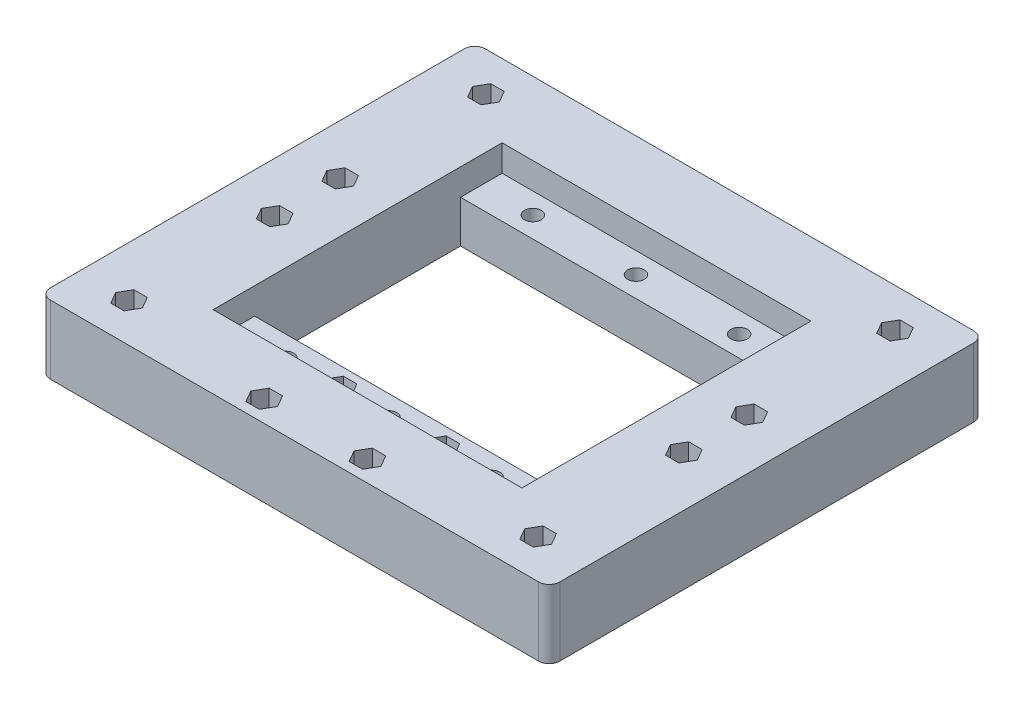
from build123d import *

# Parameters (mm, degrees)
SKETCH2_W               = 122.555
SKETCH2_H               = 104.648
SKETCH2_R               = 2
SKETCH2_W_2             = 74.295
SKETCH2_H_2             = 69.53
BOSS_EXTRUDE5_DEPTH     = 16.51
SKETCH2_4_W             = 74.295
SKETCH2_4_H             = 10
SKETCH2_4_R             = 2
BOSS_EXTRUDE7_DEPTH     = 10.16
CUT_EXTRUDE1_START      = -16.51
SKETCH3_R               = 2
CUT_EXTRUDE1_DEPTH      = 6.35
FILLET1_R               = 2.54
CUT_EXTRUDE2_START      = -10.16
SKETCH4_R               = 2
CUT_EXTRUDE2_DEPTH      = 6.35
SKETCH5_R               = 2
CUT_EXTRUDE3_DEPTH      = 6.35
SKETCH6_R               = 2
CUT_EXTRUDE4_DEPTH      = 6.35
SKETCH7_R               = 2.254
SKETCH7_R_2             = 2
SUPPORTS_3D_PRINT_DEPTH = 6.35


with BuildPart() as part:
    # Sketch2 → Boss-Extrude5 (new body)
    with BuildSketch(Plane(origin=(0, 0, 0), x_dir=(1, 0, 0), z_dir=(0, 1, 0))):
        with Locations((61.2775, 52.324)):
            Rectangle(SKETCH2_W, SKETCH2_H)
        with Locations((12.065, 95.25)):
            Circle(SKETCH2_R, mode=Mode.SUBTRACT)
        with Locations((12.065, 60.198)):
            Circle(SKETCH2_R, mode=Mode.SUBTRACT)
        with Locations((12.065, 44.45)):
            Circle(SKETCH2_R, mode=Mode.SUBTRACT)
        with Locations((12.065, 9.398)):
            Circle(SKETCH2_R, mode=Mode.SUBTRACT)
        with Locations((110.49, 9.398)):
            Circle(SKETCH2_R, mode=Mode.SUBTRACT)
        with Locations((110.49, 44.45)):
            Circle(SKETCH2_R, mode=Mode.SUBTRACT)
        with Locations((110.49, 60.198)):
            Circle(SKETCH2_R, mode=Mode.SUBTRACT)
        with Locations((110.49, 95.25)):
            Circle(SKETCH2_R, mode=Mode.SUBTRACT)
        with Locations((73.744666667, 5.08)):
            Circle(SKETCH2_R, mode=Mode.SUBTRACT)
        with Locations((48.839129454, 5.150105129)):
            Circle(SKETCH2_R, mode=Mode.SUBTRACT)
        with Locations((61.2775, 52.324)):
            Rectangle(SKETCH2_W_2, SKETCH2_H_2, mode=Mode.SUBTRACT)
    extrude(amount=BOSS_EXTRUDE5_DEPTH)

    # Sketch2_4 → Boss-Extrude7 (add)
    with BuildSketch(Plane(origin=(0, 0, 0), x_dir=(1, 0, 0), z_dir=(0, 1, 0))):
        with Locations((61.2775, 22.559)):
            Rectangle(SKETCH2_4_W, SKETCH2_4_H)
        with Locations((36.533666667, 22.559)):
            Circle(SKETCH2_4_R, mode=Mode.SUBTRACT)
        with Locations((48.939224409, 22.929823378)):
            Circle(SKETCH2_4_R, mode=Mode.SUBTRACT)
        with Locations((61.341, 22.559)):
            Circle(SKETCH2_4_R, mode=Mode.SUBTRACT)
        with Locations((73.744666667, 22.86)):
            Circle(SKETCH2_4_R, mode=Mode.SUBTRACT)
        with Locations((86.148333333, 22.559)):
            Circle(SKETCH2_4_R, mode=Mode.SUBTRACT)
        with Locations((61.2775, 82.089)):
            Rectangle(SKETCH2_4_W, SKETCH2_4_H)
        with Locations((36.533666667, 82.089)):
            Circle(SKETCH2_4_R, mode=Mode.SUBTRACT)
        with Locations((61.341, 82.089)):
            Circle(SKETCH2_4_R, mode=Mode.SUBTRACT)
        with Locations((86.148333333, 82.089)):
            Circle(SKETCH2_4_R, mode=Mode.SUBTRACT)
    extrude(amount=BOSS_EXTRUDE7_DEPTH)

    # Sketch3 → Cut-Extrude1 (cut)
    with BuildSketch(Plane.XZ.offset(CUT_EXTRUDE1_START)):
        Polygon((13.678116652, -6.604), (10.451883348, -6.604), (8.838766696, -9.398), (10.451883348, -12.192), (13.678116652, -12.192), (15.291233304, -9.398), align=None)
        with Locations((12.065, -9.398)):
            Circle(SKETCH3_R, mode=Mode.SUBTRACT)
        Polygon((13.678116652, -92.456), (10.451883348, -92.456), (8.838766696, -95.25), (10.451883348, -98.044), (13.678116652, -98.044), (15.291233304, -95.25), align=None)
        with Locations((12.065, -95.25)):
            Circle(SKETCH3_R, mode=Mode.SUBTRACT)
        Polygon((112.103116652, -92.456), (108.876883348, -92.456), (107.263766696, -95.25), (108.876883348, -98.044), (112.103116652, -98.044), (113.716233304, -95.25), align=None)
        with Locations((110.49, -95.25)):
            Circle(SKETCH3_R, mode=Mode.SUBTRACT)
        Polygon((108.876883348, -12.192), (112.103116652, -12.192), (113.716233304, -9.398), (112.103116652, -6.604), (108.876883348, -6.604), (107.263766696, -9.398), align=None)
        with Locations((110.49, -9.398)):
            Circle(SKETCH3_R, mode=Mode.SUBTRACT)
        Polygon((13.678116652, -62.992), (15.291233304, -60.198), (13.678116652, -57.404), (10.451883348, -57.404), (8.838766696, -60.198), (10.451883348, -62.992), align=None)
        with Locations((12.065, -60.198)):
            Circle(SKETCH3_R, mode=Mode.SUBTRACT)
        Polygon((8.838766696, -44.45), (10.451883348, -47.244), (13.678116652, -47.244), (15.291233304, -44.45), (13.678116652, -41.656), (10.451883348, -41.656), align=None)
        with Locations((12.065, -44.45)):
            Circle(SKETCH3_R, mode=Mode.SUBTRACT)
        Polygon((107.263766696, -44.45), (108.876883348, -47.244), (112.103116652, -47.244), (113.716233304, -44.45), (112.103116652, -41.656), (108.876883348, -41.656), align=None)
        with Locations((110.49, -44.45)):
            Circle(SKETCH3_R, mode=Mode.SUBTRACT)
        Polygon((108.876883348, -57.404), (107.263766696, -60.198), (108.876883348, -62.992), (112.103116652, -62.992), (113.716233304, -60.198), (112.103116652, -57.404), align=None)
        with Locations((110.49, -60.198)):
            Circle(SKETCH3_R, mode=Mode.SUBTRACT)
    extrude(amount=CUT_EXTRUDE1_DEPTH, mode=Mode.SUBTRACT)

    # Fillet1
    fillet1_edges = [part.edges().sort_by_distance(p)[0] for p in [
        (0, 8.255, 0),
        (0, 8.255, -104.648),
        (122.555, 8.255, -104.648),
        (122.555, 8.255, 0),
    ]]
    fillet(fillet1_edges, radius=FILLET1_R)

    # Sketch4 → Cut-Extrude2 (cut)
    with BuildSketch(Plane(origin=(0, 10.16, 0), x_dir=(1, 0, 0), z_dir=(0, 1, 0)).offset(CUT_EXTRUDE2_START)):
        Polygon((39.759899971, 22.559), (38.146783319, 25.353), (34.920550015, 25.353), (33.307433362, 22.559), (34.920550015, 19.765), (38.146783319, 19.765), align=None)
        with Locations((36.533666667, 22.559)):
            Circle(SKETCH4_R, mode=Mode.SUBTRACT)
        Polygon((58.114766696, 22.559), (59.727883348, 19.765), (62.954116652, 19.765), (64.567233304, 22.559), (62.954116652, 25.353), (59.727883348, 25.353), align=None)
        with Locations((61.341, 22.559)):
            Circle(SKETCH4_R, mode=Mode.SUBTRACT)
        Polygon((82.922100029, 22.559), (84.535216681, 19.765), (87.761449985, 19.765), (89.374566638, 22.559), (87.761449985, 25.353), (84.535216681, 25.353), align=None)
        with Locations((86.148333333, 22.559)):
            Circle(SKETCH4_R, mode=Mode.SUBTRACT)
        Polygon((82.922100029, 82.089), (84.535216681, 79.295), (87.761449985, 79.295), (89.374566638, 82.089), (87.761449985, 84.883), (84.535216681, 84.883), align=None)
        with Locations((86.148333333, 82.089)):
            Circle(SKETCH4_R, mode=Mode.SUBTRACT)
        Polygon((64.567233304, 82.089), (62.954116652, 84.883), (59.727883348, 84.883), (58.114766696, 82.089), (59.727883348, 79.295), (62.954116652, 79.295), align=None)
        with Locations((61.341, 82.089)):
            Circle(SKETCH4_R, mode=Mode.SUBTRACT)
        Polygon((39.759899971, 82.089), (38.146783319, 84.883), (34.920550015, 84.883), (33.307433362, 82.089), (34.920550015, 79.295), (38.146783319, 79.295), align=None)
        with Locations((36.533666667, 82.089)):
            Circle(SKETCH4_R, mode=Mode.SUBTRACT)
    extrude(amount=CUT_EXTRUDE2_DEPTH, mode=Mode.SUBTRACT)

    # Sketch5 → Cut-Extrude3 (cut)
    with BuildSketch(Plane(origin=(0, 10.16, 0), x_dir=(1, 0, 0), z_dir=(0, 1, 0))):
        with Locations((48.839129454, 5.150105129)):
            Circle(SKETCH5_R)
        with Locations((73.744666667, 5.08)):
            Circle(SKETCH5_R)
        Polygon((76.970899971, 22.86), (75.357783319, 25.654), (72.131550015, 25.654), (70.518433362, 22.86), (72.131550015, 20.066), (75.357783319, 20.066), align=None)
        with Locations((73.744666667, 22.86)):
            Circle(SKETCH5_R, mode=Mode.SUBTRACT)
        Polygon((52.165457714, 22.929823378), (50.552341061, 25.723823378), (47.326107757, 25.723823378), (45.712991105, 22.929823378), (47.326107757, 20.135823378), (50.552341061, 20.135823378), align=None)
        with Locations((48.939224409, 22.929823378)):
            Circle(SKETCH5_R, mode=Mode.SUBTRACT)
    extrude(amount=-CUT_EXTRUDE3_DEPTH, mode=Mode.SUBTRACT)

    # Sketch6 → Cut-Extrude4 (cut)
    with BuildSketch(Plane(origin=(0, 16.51, 0), x_dir=(1, 0, 0), z_dir=(0, 1, 0))):
        Polygon((70.518433362, 5.08), (72.131550015, 2.286), (75.357783319, 2.286), (76.970899971, 5.08), (75.357783319, 7.874), (72.131550015, 7.874), align=None)
        with Locations((73.744666667, 5.08)):
            Circle(SKETCH6_R, mode=Mode.SUBTRACT)
        Polygon((45.612896149, 5.150105129), (47.226012801, 2.356105129), (50.452246106, 2.356105129), (52.065362758, 5.150105129), (50.452246106, 7.944105129), (47.226012801, 7.944105129), align=None)
        with Locations((48.839129454, 5.150105129)):
            Circle(SKETCH6_R, mode=Mode.SUBTRACT)
    extrude(amount=-CUT_EXTRUDE4_DEPTH, mode=Mode.SUBTRACT)

    # Sketch7 → Supports - 3D Print (add)
    with BuildSketch(Plane.XZ.offset(-6.35)):
        with Locations((36.533666667, -82.089)):
            Circle(SKETCH7_R)
        with Locations((36.533666667, -82.089)):
            Circle(SKETCH7_R_2, mode=Mode.SUBTRACT)
        with Locations((61.341, -82.089)):
            Circle(SKETCH7_R)
        with Locations((61.341, -82.089)):
            Circle(SKETCH7_R_2, mode=Mode.SUBTRACT)
        with Locations((86.148333333, -82.089)):
            Circle(SKETCH7_R)
        with Locations((86.148333333, -82.089)):
            Circle(SKETCH7_R_2, mode=Mode.SUBTRACT)
        with Locations((86.148333333, -22.559)):
            Circle(SKETCH7_R)
        with Locations((86.148333333, -22.559)):
            Circle(SKETCH7_R_2, mode=Mode.SUBTRACT)
        with Locations((61.341, -22.559)):
            Circle(SKETCH7_R)
        with Locations((61.341, -22.559)):
            Circle(SKETCH7_R_2, mode=Mode.SUBTRACT)
        with Locations((36.533666667, -22.559)):
            Circle(SKETCH7_R)
        with Locations((36.533666667, -22.559)):
            Circle(SKETCH7_R_2, mode=Mode.SUBTRACT)
    extrude(amount=SUPPORTS_3D_PRINT_DEPTH)


solid = part.part
